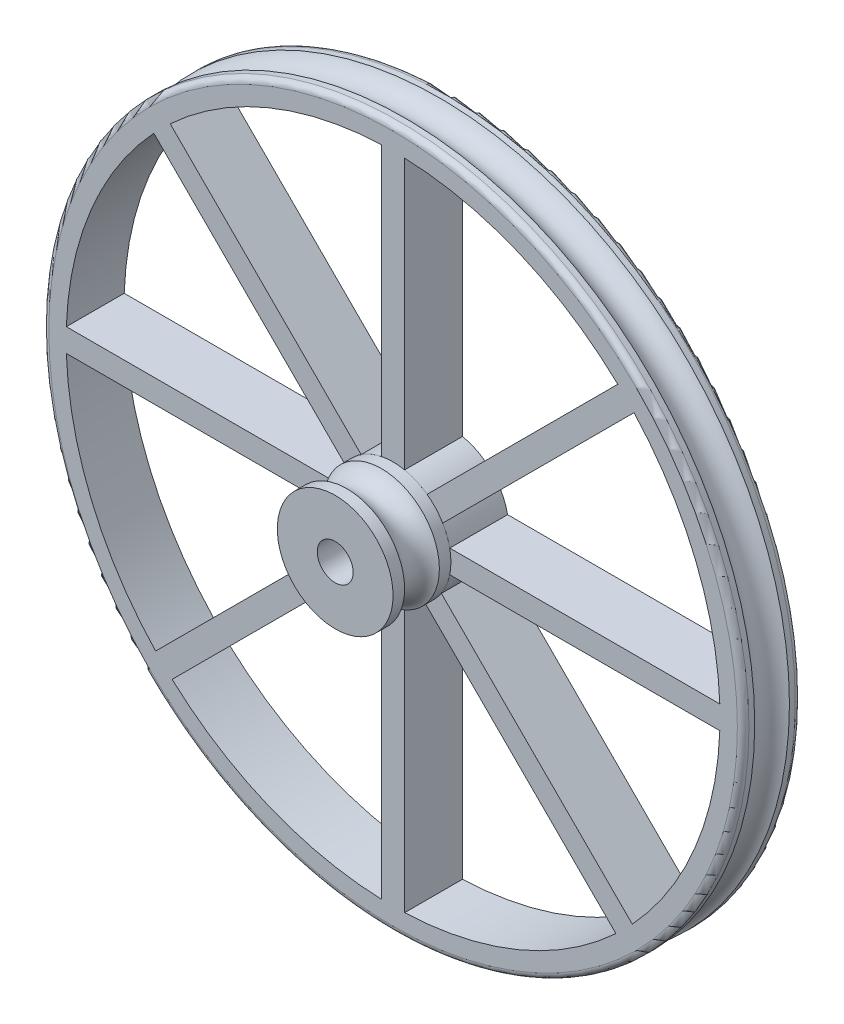
from build123d import *

# Parameters (mm, degrees)
SKETCH7_R          = 1.55
CUT_EXTRUDE1_DEPTH = 10
CUT_EXTRUDE2_DEPTH = 5
FILLET1_R          = 0.5


with BuildPart() as part:
    # Sketch4 → Revolve1 (revolve)
    with BuildSketch(Plane(origin=(0, 0, 0), x_dir=(0, 0, -1), z_dir=(1, 0, 0))):
        with BuildLine():
            Line((-5, 30.25), (-4, 30.25))
            ThreePointArc((-4, 30.25), (-2.5, 29.25), (-1, 30.25))
            Line((-1, 30.25), (0, 30.25))
            Line((0, 30.25), (0, 0))
            Line((0, 0), (-5, 0))
            Line((-5, 0), (-5, 30.25))
        make_face()
    revolve(axis=Axis((0, 0, 5), (0, 0, -1)))


with BuildPart() as body_2:
    # Sketch6 → Revolve2 (revolve)
    with BuildSketch(Plane(origin=(0, 0, 0), x_dir=(0, 0, -1), z_dir=(1, 0, 0))):
        with BuildLine():
            Line((-5, 0), (-5, 5))
            Line((-5, 5), (-6, 5))
            ThreePointArc((-6, 5), (-7.5, 4), (-9, 5))
            Line((-9, 5), (-10, 5))
            Line((-10, 5), (-10, 0))
            Line((-10, 0), (-5, 0))
        make_face()
    revolve(axis=Axis((0, 0, 10), (0, 0, -1)))


with BuildPart() as cut_extrude1_tool:
    # Sketch7 → Cut-Extrude1 (new body)
    with BuildSketch(Plane.XY):
        Circle(SKETCH7_R)
    extrude(amount=CUT_EXTRUDE1_DEPTH)


with BuildPart() as part_1:
    add(part.part)

    # Cut-Extrude1: cut by cut_extrude1_tool
    add(cut_extrude1_tool.part, mode=Mode.SUBTRACT)

    # Sketch8 → Cut-Extrude2 (cut)
    with BuildSketch(Plane.XY):
        with BuildLine():
            Line((4.898979486, 1), (28.232295337, 1))
            ThreePointArc((28.232295337, 1), (26.141896401, 10.708116199), (20.821120243, 19.093021024))
            Line((20.821120243, 19.093021024), (4.29237548, 2.564276261))
            ThreePointArc((4.29237548, 2.564276261), (4.661758421, 1.807763375), (4.898979486, 1))
        make_face()
        with BuildLine():
            Line((1, 4.898979486), (1, 28.232295337))
            ThreePointArc((1, 28.232295337), (10.913302118, 26.056905743), (19.418024989, 20.518352895))
            Line((19.418024989, 20.518352895), (2.942302171, 4.042630076))
            ThreePointArc((2.942302171, 4.042630076), (2.017119277, 4.5750661), (1, 4.898979486))
        make_face()
        with BuildLine():
            Line((4.898979486, -1), (28.232295337, -1))
            ThreePointArc((28.232295337, -1), (26.099596793, -10.810806964), (20.670354262, -19.2561407))
            Line((20.670354262, -19.2561407), (4.171208396, -2.756994834))
            ThreePointArc((4.171208396, -2.756994834), (4.619397663, -1.913417162), (4.898979486, -1))
        make_face()
        with BuildLine():
            Line((1, -4.898979486), (1, -28.232295337))
            ThreePointArc((1, -28.232295337), (10.810806964, -26.099596793), (19.2561407, -20.670354262))
            Line((19.2561407, -20.670354262), (2.756994834, -4.171208396))
            ThreePointArc((2.756994834, -4.171208396), (1.913417162, -4.619397663), (1, -4.898979486))
        make_face()
        with BuildLine():
            Line((-1, -28.232295337), (-1, -4.898979486))
            ThreePointArc((-1, -4.898979486), (-1.807763375, -4.661758421), (-2.564276261, -4.29237548))
            Line((-2.564276261, -4.29237548), (-19.093021024, -20.821120243))
            ThreePointArc((-19.093021024, -20.821120243), (-10.708116199, -26.141896401), (-1, -28.232295337))
        make_face()
        with BuildLine():
            Line((-28.232295337, -1), (-4.898979486, -1))
            ThreePointArc((-4.898979486, -1), (-4.5750661, -2.017119277), (-4.042630076, -2.942302171))
            Line((-4.042630076, -2.942302171), (-20.518352895, -19.418024989))
            ThreePointArc((-20.518352895, -19.418024989), (-26.056905743, -10.913302118), (-28.232295337, -1))
        make_face()
        with BuildLine():
            Line((-28.232295337, 1), (-4.898979486, 1))
            ThreePointArc((-4.898979486, 1), (-4.619397663, 1.913417162), (-4.171208396, 2.756994834))
            Line((-4.171208396, 2.756994834), (-20.670354262, 19.2561407))
            ThreePointArc((-20.670354262, 19.2561407), (-26.099596793, 10.810806964), (-28.232295337, 1))
        make_face()
        with BuildLine():
            Line((-1, 4.898979486), (-1, 28.232295337))
            ThreePointArc((-1, 28.232295337), (-10.810806964, 26.099596793), (-19.2561407, 20.670354262))
            Line((-19.2561407, 20.670354262), (-2.756994834, 4.171208396))
            ThreePointArc((-2.756994834, 4.171208396), (-1.913417162, 4.619397663), (-1, 4.898979486))
        make_face()
    extrude(amount=CUT_EXTRUDE2_DEPTH, mode=Mode.SUBTRACT)

    # Fillet1
    fillet1_edges = [part_1.edges().sort_by_distance(p)[0] for p in [
        (0, -30.25, 5),
        (0, -30.25, 0),
    ]]
    fillet(fillet1_edges, radius=FILLET1_R)


with BuildPart() as body_2_1:
    add(body_2.part)

    # Cut-Extrude1: cut by cut_extrude1_tool
    add(cut_extrude1_tool.part, mode=Mode.SUBTRACT)


solid = Compound([part_1.part, body_2_1.part])
